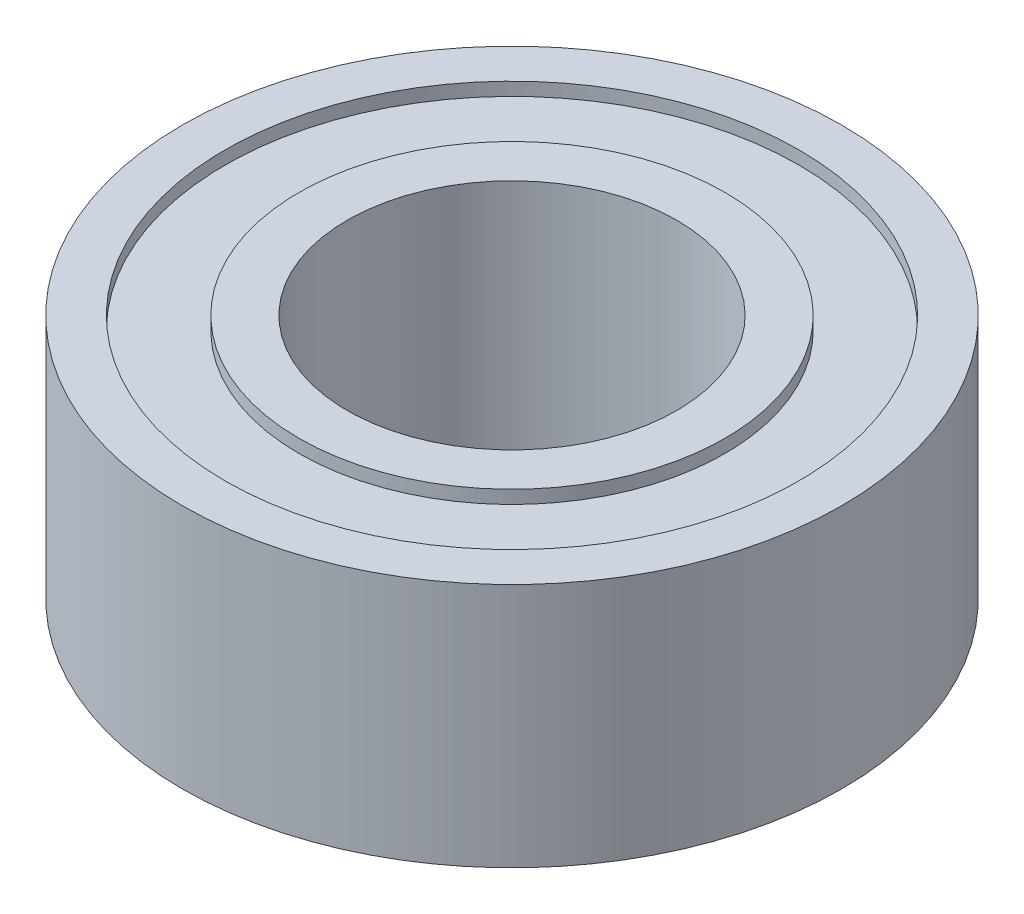
from build123d import *


with BuildPart() as part:
    # Sketch1 → Revolve1 (revolve)
    with BuildSketch(Plane.XY):
        Polygon((4.1021, 4.7244), (3.175, 4.7244), (3.175, 0), (4.1021, 0), (4.1021, 0.254), (5.5245, 0.254), (5.5245, 0), (6.35, 0), (6.35, 4.7244), (5.5245, 4.7244), (5.5245, 4.4704), (4.1021, 4.4704), align=None)
    revolve(axis=Axis((0, 4.7244, 0), (0, -1, 0)))


solid = part.part
